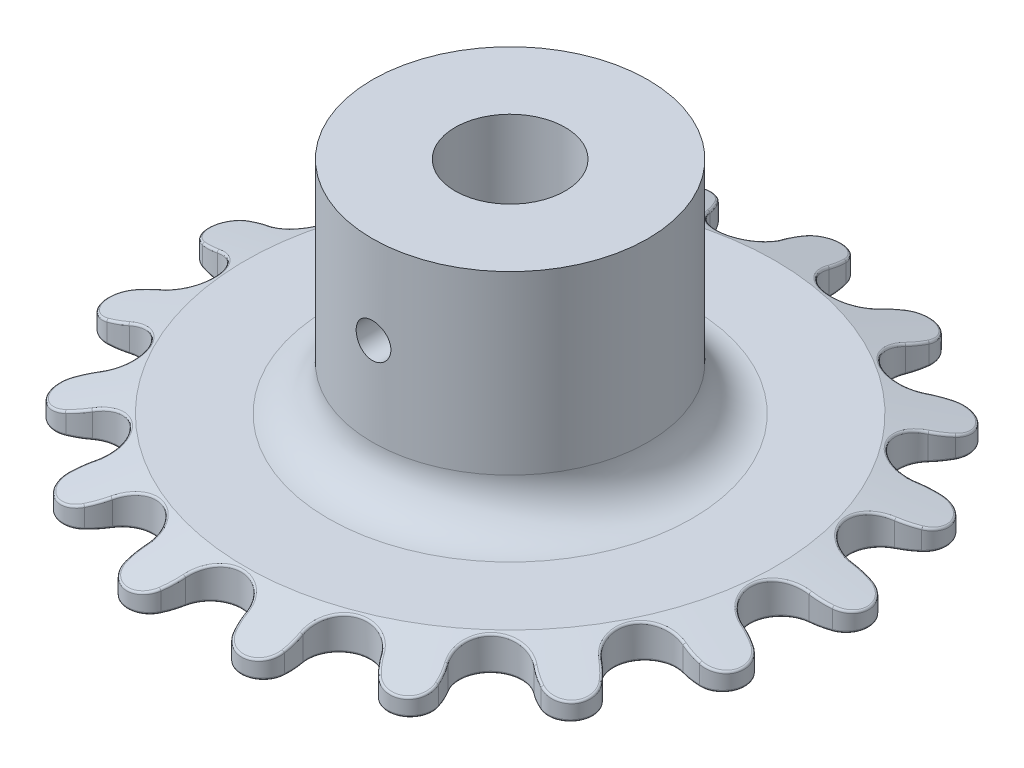
from build123d import *

# Parameters (mm, degrees)
BOSS_EXTRUDE1_DEPTH     = 1.016
CIRPATTERN1_COUNT       = 17
SKETCH3_R               = 3.175
CUT_EXTRUDE1_DEPTH      = 3.032
SKETCH2_R               = 7.9375
SKETCH2_R_2             = 3.175
BOSS_EXTRUDE2_DEPTH     = 12.7
FILLET1_R               = 2.54
SKETCH4_R               = 1
CUT_EXTRUDE2_DEPTH      = 19.781323654
CUT_EXTRUDE2_DEPTH_BACK = 20.084180396
FILLET2_R               = 0.127


with BuildPart() as part:
    # Sketch1 → Boss-Extrude1 (new body, symmetric)
    with BuildSketch(Plane(origin=(0, 0, 0), x_dir=(1, 0, 0), z_dir=(0, 1, 0))):
        with BuildLine():
            ThreePointArc((-1.397, 16.98474983), (-1.8071242, 15.84888021), (-2.848293357, 15.237023659))
            Line((-2.848293357, 15.237023659), (0, 0))
            Line((0, 0), (2.848293357, 15.237023659))
            ThreePointArc((2.848293357, 15.237023659), (1.8071242, 15.84888021), (1.397, 16.98474983))
            ThreePointArc((1.397, 16.98474983), (1.362041207, 17.549055672), (1.257699439, 18.104731833))
            ThreePointArc((1.257699439, 18.104731833), (0, 19.084180396), (-1.257699439, 18.104731833))
            ThreePointArc((-1.257699439, 18.104731833), (-1.362041207, 17.549055672), (-1.397, 16.98474983))
        make_face()
    boss_extrude1 = extrude(amount=BOSS_EXTRUDE1_DEPTH, both=True)

    # CirPattern1: Boss-Extrude1 ×17 about axis
    cirpattern1_axis = Axis((0, 0, 0), (0, 1, 0))
    for i in range(1, CIRPATTERN1_COUNT):
        add(boss_extrude1.rotate(cirpattern1_axis, i * 360 / CIRPATTERN1_COUNT))

    # Sketch3 → Cut-Extrude1 (cut, through all)
    with BuildSketch(Plane(origin=(0, 1.016, 0), x_dir=(1, 0, 0), z_dir=(0, 1, 0))):
        Circle(SKETCH3_R)
    extrude(amount=-CUT_EXTRUDE1_DEPTH, mode=Mode.SUBTRACT)

    # Sketch2 → Boss-Extrude2 (add)
    with BuildSketch(Plane(origin=(0, 1.016, 0), x_dir=(1, 0, 0), z_dir=(0, 1, 0))):
        Circle(SKETCH2_R)
        Circle(SKETCH2_R_2, mode=Mode.SUBTRACT)
    extrude(amount=BOSS_EXTRUDE2_DEPTH)

    # Fillet1
    fillet1_edges = [part.edges().sort_by_distance(p)[0] for p in [
        (-7.9375, 1.016, 0),
    ]]
    fillet(fillet1_edges, radius=FILLET1_R)

    # Sketch4 → Cut-Extrude2 (cut, two sides)
    with BuildSketch(Plane.XY) as cut_extrude2_sk:
        with Locations((0, 8.636)):
            Circle(SKETCH4_R)
    extrude(amount=CUT_EXTRUDE2_DEPTH, mode=Mode.SUBTRACT)
    extrude(cut_extrude2_sk.sketch, amount=-CUT_EXTRUDE2_DEPTH_BACK, mode=Mode.SUBTRACT)

    # Sketch5 → Cut-Revolve1 (revolve, cut)
    with BuildSketch(Plane(origin=(0, 0, 0), x_dir=(0, 0, -1), z_dir=(1, 0, 0))):
        Polygon((19.084180396, 0), (19.084180396, 1.016), (18.104731833, 1.016), (15.274180396, 1.016), align=None)
    revolve(axis=Axis((0, 0, 0), (0, 1, 0)), mode=Mode.SUBTRACT)

    # Fillet2
    fillet2_edges = [part.edges().sort_by_distance(p)[0] for p in [
        (-1.362041207, -1.016, -17.549055672),
        (0, -1.016, -19.084180396),
        (1.362041207, -1.016, -17.549055672),
        (2.848293357, -1.016, -15.237023659),
        (-7.609411239, 0.395404846, -15.871564909),
        (7.609515712, -1.016, -15.871981031),
        (-4.563454155, 0.395404846, 16.999547001),
        (1.885650414, 0.395404846, 17.500115273),
        (8.080087445, 0.395404846, 15.637196006),
        (-10.396238952, 0.395404846, 14.203095708),
        (13.183263893, 0.395404846, 11.66238677),
        (-14.824954072, 0.395404846, 9.488437638),
        (16.505967502, 0.395404846, 6.112507577),
        (17.599448737, 0.395404846, -0.262899635),
        (-17.251476996, 0.395404846, 3.492313488),
        (16.316026898, 0.395404846, -6.602800794),
        (-17.348092359, 0.395404846, -2.97546695),
        (12.829035216, 0.395404846, -12.050957119),
        (7.60941124, 0.395404846, -15.871564908),
        (-15.101751719, 0.395404846, -9.04139409),
        (1.362094111, 0.395404846, -17.548629909),
        (-10.815835828, 0.395404846, -13.886230857),
        (-5.069181375, 0.395404846, -16.855655201),
        (-3.506708947, 0, 18.759235959),
        (-5.5995915, 0.955526264, 14.454211845),
        (-8.080087446, 0.395404846, 15.637196006),
        (-10.046526363, 0, 16.225697194),
        (-10.44292714, 0.955526264, 11.45534538),
        (-13.183263894, 0.395404846, 11.66238677),
        (-15.229504725, 0, 11.500788114),
        (-13.875887604, 0.955526264, 6.909371045),
        (-16.505967502, 0.395404846, 6.112507576),
        (-18.355654084, 0, 5.22263387),
        (-15.434832557, 0.955526264, 1.430247864),
        (-17.599448737, 0.395404846, -0.262899636),
        (-19.002770647, 0, -1.760866017),
        (-14.909217847, 0.955526264, -4.242038216),
        (-16.316026898, 0.395404846, -6.602800795),
        (-17.083457736, 0, -8.506551191),
        (-12.370030651, 0.955526264, -9.341413529),
        (-12.829035215, 0.395404846, -12.05095712),
        (-12.856929196, 0, -14.103379491),
        (-8.160202271, 0.955526264, -13.179179182),
        (-6.894001125, 0, -17.79546824),
        (-2.848293357, 0.955526264, -15.237023659),
        (-1.36209411, 0.395404846, -17.548629909),
        (0.803126159, 0.069698246, -18.805670396),
        (2.848293357, 0.955526264, -15.237023659),
        (5.069181376, 0.395404846, -16.8556552),
        (6.894001124, 0, -17.79546824),
        (8.160202271, 0.955526264, -13.179179182),
        (10.815835828, 0.395404846, -13.886230856),
        (12.856929196, 0, -14.103379491),
        (12.370030651, 0.955526264, -9.341413529),
        (15.101751719, 0.395404846, -9.041394089),
        (17.083457736, 0, -8.506551191),
        (14.909217847, 0.955526264, -4.242038216),
        (17.348092359, 0.395404846, -2.97546695),
        (19.002770647, 0, -1.760866017),
        (15.434832557, 0.955526264, 1.430247864),
        (17.251476996, 0.395404846, 3.492313489),
        (18.355654084, 0, 5.22263387),
        (13.875887604, 0.955526264, 6.909371045),
        (14.824954072, 0.395404846, 9.488437639),
        (15.229504725, 0, 11.500788114),
        (10.442927141, 0.955526264, 11.45534538),
        (10.396238952, 0.395404846, 14.203095709),
        (10.046526363, 0, 16.225697194),
        (5.599591501, 0.955526264, 14.454211845),
        (4.563454154, 0.395404846, 16.999547001),
        (3.506708946, 0, 18.759235959),
        (0, 0.955526264, 15.500956907),
        (-1.885650414, 0.395404846, 17.500115273),
        (8.160202271, -1.016, -13.179179182),
        (10.816161758, -1.016, -13.886509858),
        (12.856929196, -1.016, -14.103379491),
        (12.370030651, -1.016, -9.341413529),
        (15.102156427, -1.016, -9.041536511),
        (17.083457736, -1.016, -8.506551191),
        (14.909217847, -1.016, -4.242038216),
        (17.348521187, -1.016, -2.975453557),
        (19.002770647, -1.016, -1.760866017),
        (15.434832557, -1.016, 1.430247864),
        (17.251872028, -1.016, 3.492480888),
        (18.355654084, -1.016, 5.22263387),
        (13.875887604, -1.016, 6.909371045),
        (14.825261956, -1.016, 9.488736436),
        (15.229504725, -1.016, 11.500788114),
        (10.44292714, -1.016, 11.45534538),
        (10.396418108, -1.016, 14.203485549),
        (10.046526363, -1.016, 16.225697194),
        (5.599591501, -1.016, 14.454211845),
        (4.563480385, -1.016, 16.999975235),
        (3.506708946, -1.016, 18.759235959),
        (0, -1.016, 15.500956907),
        (-1.88578065, -1.016, 17.500524065),
        (-3.506708946, -1.016, 18.759235959),
        (-5.599591501, -1.016, 14.454211845),
        (-8.08035656, -1.016, 15.637530147),
        (-10.046526363, -1.016, 16.225697194),
        (-10.44292714, -1.016, 11.45534538),
        (-13.183635541, -1.016, 11.662601131),
        (-15.229504725, -1.016, 11.500788114),
        (-13.875887604, -1.016, 6.909371045),
        (-16.506391489, -1.016, 6.112573208),
        (-18.355654084, -1.016, 5.22263387),
        (-15.434832557, -1.016, 1.430247864),
        (-17.599867802, -1.016, -0.262991597),
        (-19.002770647, -1.016, -1.760866017),
        (-14.909217847, -1.016, -4.242038216),
        (-16.316384444, -1.016, -6.603037931),
        (-17.083457736, -1.016, -8.506551191),
        (-12.370030651, -1.016, -9.341413529),
        (-12.829282954, -1.016, -12.051307403),
        (-12.856929196, -1.016, -14.103379491),
        (-8.160202271, -1.016, -13.179179182),
        (-7.609515712, -1.016, -15.871981031),
        (-6.894001124, -1.016, -17.79546824),
        (5.06938451, -1.016, -16.856033102),
        (6.894001124, -1.016, -17.79546824),
        (12.829282954, -1.016, -12.051307403),
        (16.316384444, -1.016, -6.603037931),
        (17.599867802, -1.016, -0.262991597),
        (16.506391489, -1.016, 6.112573208),
        (13.183635541, -1.016, 11.662601131),
        (8.08035656, -1.016, 15.637530147),
        (1.88578065, -1.016, 17.500524065),
        (-4.563480385, -1.016, 16.999975235),
        (-10.396418108, -1.016, 14.203485549),
        (-14.825261956, -1.016, 9.488736436),
        (-17.251872028, -1.016, 3.492480888),
        (-17.348521187, -1.016, -2.975453557),
        (-15.102156427, -1.016, -9.041536511),
        (-10.816161758, -1.016, -13.886509858),
        (-5.06938451, -1.016, -16.856033102),
        (-2.848293357, -1.016, -15.237023659),
    ]]
    fillet(fillet2_edges, radius=FILLET2_R)


solid = part.part
